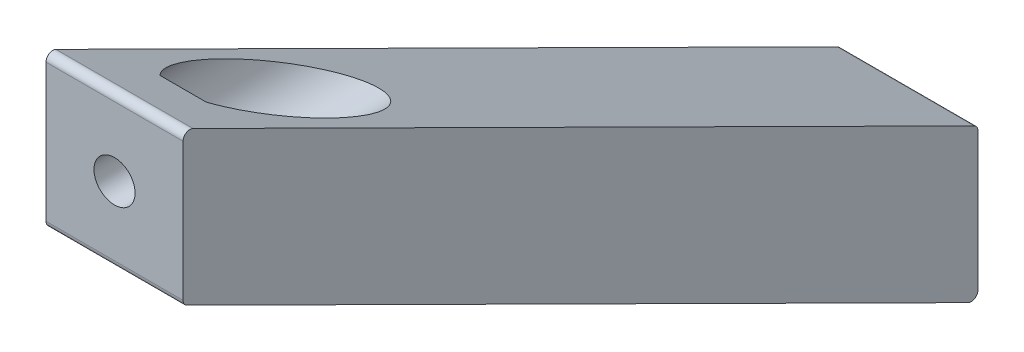
from build123d import *

# Parameters (mm, degrees)
BOSS_EXTRUDE1_DEPTH = 20
SKETCH2_R           = 3
CUT_EXTRUDE5_DEPTH  = 117
CUT_EXTRUDE6_START  = -10
SKETCH5_R           = 7.5
CUT_EXTRUDE6_DEPTH  = 107
SKETCH6_R           = 3
CUT_EXTRUDE7_DEPTH  = 117
CUT_EXTRUDE8_START  = -10
SKETCH7_R           = 7.5
CUT_EXTRUDE8_DEPTH  = 107


with BuildPart() as part:
    # Sketch1 → Boss-Extrude1 (new body)
    with BuildSketch(Plane(origin=(0, 0, 0), x_dir=(0, 0, -1), z_dir=(1, 0, 0))):
        with BuildLine():
            Line((0.554855898, 101.68431358), (114.554855898, 45.013454735))
            ThreePointArc((114.554855898, 45.013454735), (115.526714295, 45.058871302), (116, 45.908913684))
            Line((116, 45.908913684), (116, 66.010337689))
            ThreePointArc((116, 66.010337689), (115.850042382, 66.537051984), (115.445144102, 66.905796637))
            Line((115.445144102, 66.905796637), (1.445144102, 123.576655482))
            ThreePointArc((1.445144102, 123.576655482), (0.473285705, 123.531238916), (0, 122.681196534))
            Line((0, 122.681196534), (0, 102.579772529))
            ThreePointArc((0, 102.579772529), (0.149957618, 102.053058233), (0.554855898, 101.68431358))
        make_face()
    extrude(amount=BOSS_EXTRUDE1_DEPTH)

    # Sketch2 → Cut-Extrude5 (cut, through all)
    with BuildSketch(Plane.XY):
        with Locations((10, 112.630484531)):
            Circle(SKETCH2_R)
    extrude(amount=-CUT_EXTRUDE5_DEPTH, mode=Mode.SUBTRACT)

    # Sketch5 → Cut-Extrude6 (cut, through all)
    with BuildSketch(Plane.XY.offset(CUT_EXTRUDE6_START)):
        with Locations((10, 112.630484531)):
            Circle(SKETCH5_R)
    extrude(amount=-CUT_EXTRUDE6_DEPTH, mode=Mode.SUBTRACT)

    # Sketch6 → Cut-Extrude7 (cut, through all)
    with BuildSketch(Plane(origin=(0, 0, -116), x_dir=(-1, 0, 0), z_dir=(0, 0, -1))):
        with Locations((-10, 55.959625686)):
            Circle(SKETCH6_R)
    extrude(amount=-CUT_EXTRUDE7_DEPTH, mode=Mode.SUBTRACT)

    # Sketch7 → Cut-Extrude8 (cut, through all)
    with BuildSketch(Plane(origin=(0, 0, -116), x_dir=(-1, 0, 0), z_dir=(0, 0, -1)).offset(CUT_EXTRUDE8_START)):
        with Locations((-10, 55.959625686)):
            Circle(SKETCH7_R)
    extrude(amount=-CUT_EXTRUDE8_DEPTH, mode=Mode.SUBTRACT)


solid = part.part
